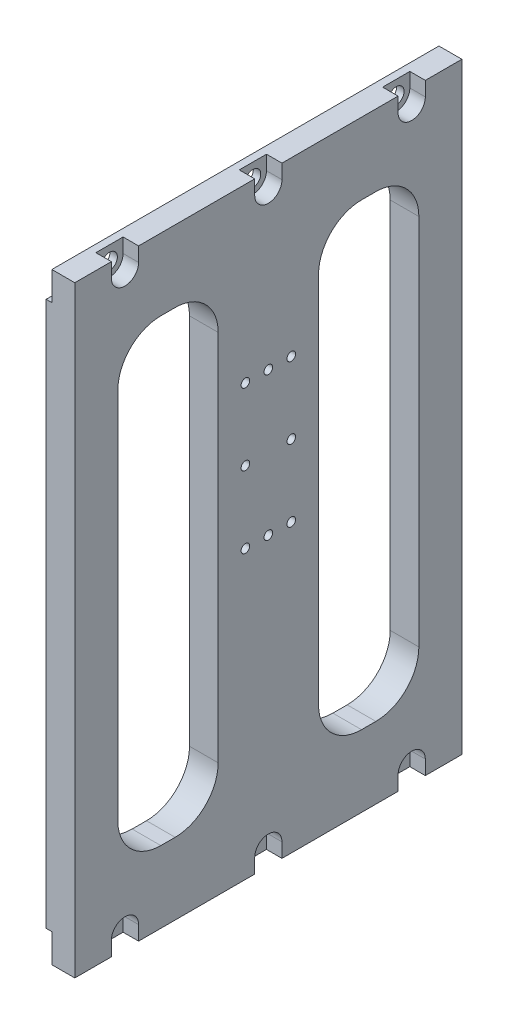
from build123d import *

# Parameters (mm, degrees)
SKETCH1_W                  = 135
SKETCH1_H                  = 210
BOSS_EXTRUDE1_DEPTH        = 10
CUT_EXTRUDE1_START         = -8
SKETCH4_W                  = 135
SKETCH4_H                  = 10
CUT_EXTRUDE1_DEPTH         = 3
SKETCH15_W                 = 35
SKETCH15_H                 = 160
CUT_EXTRUDE2_DEPTH         = 11
SKETCH16_R                 = 1.5
CUT_EXTRUDE3_DEPTH         = 5
CUT_EXTRUDE4_DEPTH         = 5.4
F_3_0_3_DIAMETER_HOLE1_D   = 3
LPATTERN4_COUNT            = 2
LPATTERN4_PITCH            = 16
LPATTERN4_COUNT_DIR2       = 3
LPATTERN4_PITCH_DIR2       = 25
LPATTERN1_COUNT            = 3
LPATTERN1_PITCH            = 50
F_5_5_5_5_DIAMETER_HOLE1_D = 5.5
LPATTERN3_COUNT            = 3
LPATTERN3_PITCH            = 50
FILLET1_R                  = 15


with BuildPart() as part:
    # Sketch1 → Boss-Extrude1 (new body)
    with BuildSketch(Plane(origin=(0, 0, 0), x_dir=(0, 0, -1), z_dir=(1, 0, 0))):
        with Locations((67.5, 105)):
            Rectangle(SKETCH1_W, SKETCH1_H)
    extrude(amount=BOSS_EXTRUDE1_DEPTH)

    # Sketch4 → Cut-Extrude1 (cut, through all)
    with BuildSketch(Plane(origin=(10, 0, 0), x_dir=(0, 0, -1), z_dir=(1, 0, 0)).offset(CUT_EXTRUDE1_START)):
        with Locations((67.5, 5)):
            Rectangle(SKETCH4_W, SKETCH4_H)
        with Locations((67.5, 205)):
            Rectangle(SKETCH4_W, SKETCH4_H)
    extrude(amount=-CUT_EXTRUDE1_DEPTH, mode=Mode.SUBTRACT)

    # Sketch15 → Cut-Extrude2 (cut, through all)
    with BuildSketch(Plane(origin=(10, 0, 0), x_dir=(0, 0, -1), z_dir=(1, 0, 0))):
        with Locations((32.5, 105)):
            Rectangle(SKETCH15_W, SKETCH15_H)
        with Locations((102.5, 105)):
            Rectangle(SKETCH15_W, SKETCH15_H)
    extrude(amount=-CUT_EXTRUDE2_DEPTH, mode=Mode.SUBTRACT)

    # Sketch16 → Cut-Extrude3 (cut)
    with BuildSketch(Plane(origin=(10, 0, 0), x_dir=(0, 0, -1), z_dir=(1, 0, 0))):
        with Locations((67.5, 100)):
            Circle(SKETCH16_R)
        with Locations((67.5, 150)):
            Circle(SKETCH16_R)
    extrude(amount=-CUT_EXTRUDE3_DEPTH, mode=Mode.SUBTRACT)

    # Sketch6 → Cut-Extrude4 (cut)
    with BuildSketch(Plane.ZY.offset(-10)):
        with BuildLine():
            Line((-22.25, 5), (-22.25, 0))
            Line((-22.25, 0), (-12.75, 0))
            Line((-12.75, 0), (-12.75, 5))
            ThreePointArc((-12.75, 5), (-17.5, 9.75), (-22.25, 5))
        make_face()
        with BuildLine():
            Line((-22.25, 205), (-22.25, 210))
            Line((-22.25, 210), (-12.75, 210))
            Line((-12.75, 210), (-12.75, 205))
            ThreePointArc((-12.75, 205), (-17.5, 200.25), (-22.25, 205))
        make_face()
    cut_extrude4 = extrude(amount=CUT_EXTRUDE4_DEPTH, mode=Mode.SUBTRACT)

    # Ø3.0 (3) Diameter Hole1 (through all)
    with Locations(Plane(origin=(10, 0, 0), x_dir=(0, 0, -1), z_dir=(1, 0, 0))):
        with Locations((59.5, 100)):
            f_3_0_3_diameter_hole1 = Hole(F_3_0_3_DIAMETER_HOLE1_D / 2)

    # LPattern4: 3.0 _3_ Diameter Hole1 2 × 3
    with Locations(*[(0, j * LPATTERN4_PITCH_DIR2, -i * LPATTERN4_PITCH) for i in range(LPATTERN4_COUNT) for j in range(LPATTERN4_COUNT_DIR2) if (i, j) != (0, 0)]):
        add(f_3_0_3_diameter_hole1, mode=Mode.SUBTRACT)

    # LPattern1: Cut-Extrude4 ×3
    with Locations(*[(0, 0, -i * LPATTERN1_PITCH) for i in range(1, LPATTERN1_COUNT)]):
        add(cut_extrude4, mode=Mode.SUBTRACT)

    # Ø5.5 (5.5) Diameter Hole1 (through all)
    with Locations(Plane(origin=(4.6, 0, 0), x_dir=(0, 0, -1), z_dir=(1, 0, 0))):
        with Locations((17.5, 205), (17.5, 5)):
            f_5_5_5_5_diameter_hole1 = Hole(F_5_5_5_5_DIAMETER_HOLE1_D / 2)

    # LPattern3: Ø5.5 (5.5) Diameter Hole1 ×3
    with Locations(*[(0, 0, -i * LPATTERN3_PITCH) for i in range(1, LPATTERN3_COUNT)]):
        add(f_5_5_5_5_diameter_hole1, mode=Mode.SUBTRACT)

    # Fillet1
    fillet1_edges = [part.edges().sort_by_distance(p)[0] for p in [
        (5, 25, -15),
        (5, 185, -15),
        (5, 185, -50),
        (5, 25, -50),
        (5, 25, -85),
        (5, 185, -85),
        (5, 185, -120),
        (5, 25, -120),
    ]]
    fillet(fillet1_edges, radius=FILLET1_R)


solid = part.part
